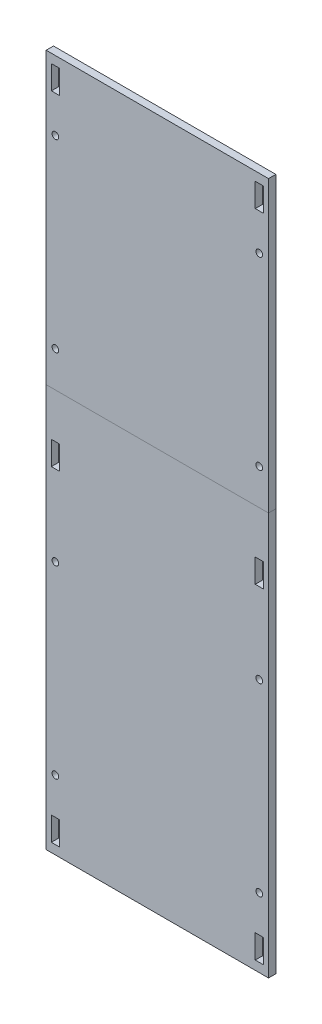
from build123d import *

# Parameters (mm, degrees)
SKETCH1_W              = 96.34
SKETCH1_H              = 300
BOSS_EXTRUDE1_DEPTH    = 1.5875
SKETCH1_3_W            = 3.4925
SKETCH1_3_H            = 10.25
CUT_EXTRUDE1_DEPTH     = 158.552750075
M2_5_CLEARANCE_HOLE1_D = 2.9
LPATTERN1_COUNT        = 4
LPATTERN1_PITCH        = 80
MIRROR1_COPY_1_D       = 2.9
MIRROR1_COPY_2_D       = 2.9
MIRROR1_COPY_3_D       = 2.9
MIRROR1_COPY_4_D       = 2.9


with BuildPart() as part:
    # Sketch1 → Boss-Extrude1 (new, symmetric)
    with BuildSketch(Plane.XY):
        Rectangle(SKETCH1_W, SKETCH1_H)
    extrude(amount=BOSS_EXTRUDE1_DEPTH, both=True)

    # Sketch1_3 → Cut-Extrude1 (cut, symmetric)
    with BuildSketch(Plane.XY):
        with Locations((-44.17, 141)):
            Rectangle(SKETCH1_3_W, SKETCH1_3_H)
        with Locations((-44.17, 0)):
            Rectangle(SKETCH1_3_W, SKETCH1_3_H)
        with Locations((-44.17, -141)):
            Rectangle(SKETCH1_3_W, SKETCH1_3_H)
    cut_extrude1 = extrude(amount=CUT_EXTRUDE1_DEPTH, both=True, mode=Mode.SUBTRACT)

    # M2.5 Clearance Hole1 (through all)
    with Locations(Plane.XY.offset(1.5875)):
        with Locations((-44.17, 120)):
            m2_5_clearance_hole1 = Hole(M2_5_CLEARANCE_HOLE1_D / 2)

    # LPattern1: M2.5 Clearance Hole1 ×4
    with Locations(*[(0, -i * LPATTERN1_PITCH, 0) for i in range(1, LPATTERN1_COUNT)]):
        add(m2_5_clearance_hole1, mode=Mode.SUBTRACT)

    # Mirror1: Cut-Extrude1 across plane
    add(cut_extrude1.mirror(Plane(origin=(0, 0, 0), x_dir=(0, 0, 1), z_dir=(1, 0, 0))), mode=Mode.SUBTRACT)

    # Mirror1 copy 1 (through all)
    with Locations(Plane(origin=(0, -80, 1.5875), x_dir=(-1, 0, 0), z_dir=(0, 0, 1))):
        with Locations((-44.17, -120)):
            Hole(MIRROR1_COPY_1_D / 2)

    # Mirror1 copy 2 (through all)
    with Locations(Plane(origin=(0, -160, 1.5875), x_dir=(-1, 0, 0), z_dir=(0, 0, 1))):
        with Locations((-44.17, -120)):
            Hole(MIRROR1_COPY_2_D / 2)

    # Mirror1 copy 3 (through all)
    with Locations(Plane(origin=(0, -240, 1.5875), x_dir=(-1, 0, 0), z_dir=(0, 0, 1))):
        with Locations((-44.17, -120)):
            Hole(MIRROR1_COPY_3_D / 2)

    # Mirror1 copy 4 (through all)
    with Locations(Plane(origin=(0, 0, 1.5875), x_dir=(-1, 0, 0), z_dir=(0, 0, 1))):
        with Locations((-44.17, -120)):
            Hole(MIRROR1_COPY_4_D / 2)


with BuildPart() as body_2:
    # Split1: the piece on the far side of the plane
    add(part.part)
    split(bisect_by=Plane.ZX.offset(24.5), keep=Keep.BOTTOM)


with BuildPart() as part_1:
    add(part.part)

    # Split1
    split(bisect_by=Plane.ZX.offset(24.5), keep=Keep.TOP)


solid = Compound([body_2.part, part_1.part])
